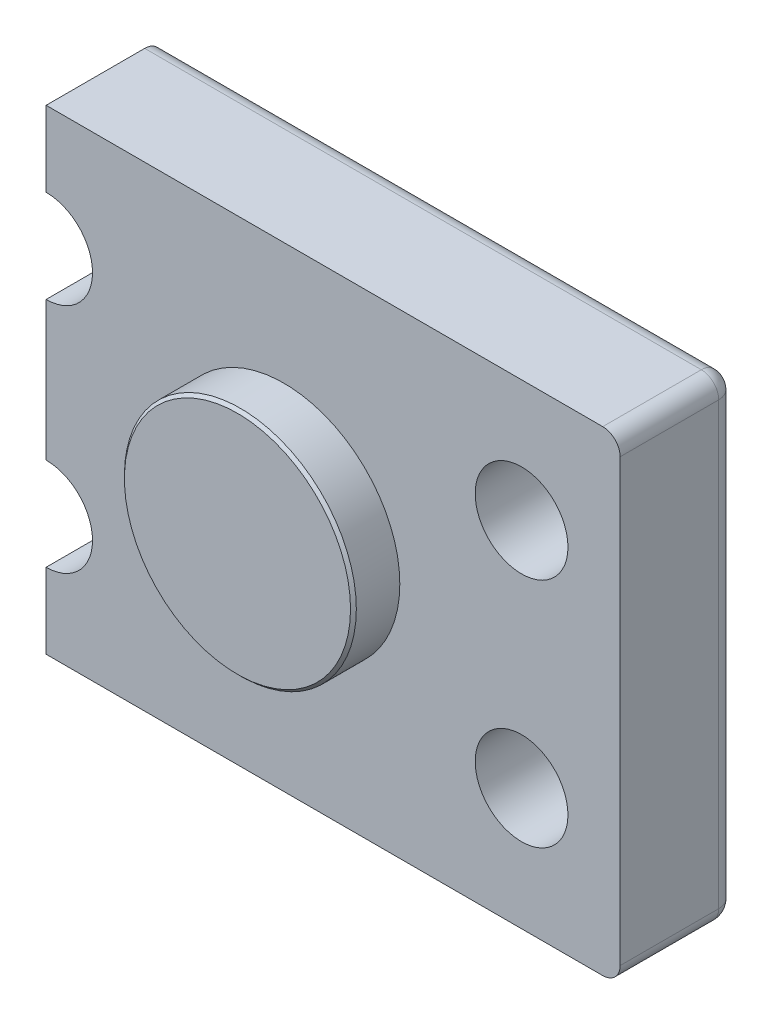
from build123d import *

# Parameters (mm, degrees)
BOSS_EXTRUDE1_DEPTH = 20
SKETCH2_R           = 8
CUT_EXTRUDE1_DEPTH  = 21
LPATTERN1_COUNT     = 2
LPATTERN1_PITCH     = 40
SKETCH3_R           = 20
BOSS_EXTRUDE2_DEPTH = 8
CHAMFER1_SIZE       = 0.5
FILLET1_R           = 3


with BuildPart() as part:
    # Sketch1 → Boss-Extrude1 (new body)
    with BuildSketch(Plane.XY):
        with BuildLine():
            Line((0, 69), (0, 82))
            Line((0, 82), (99, 82))
            Line((99, 82), (99, 0))
            Line((99, 0), (0, 0))
            Line((0, 0), (0, 13))
            ThreePointArc((0, 13), (8, 21), (0, 29))
            Line((0, 29), (0, 53))
            ThreePointArc((0, 53), (8, 61), (0, 69))
        make_face()
    extrude(amount=BOSS_EXTRUDE1_DEPTH)

    # Sketch2 → Cut-Extrude1 (cut, through all)
    with BuildSketch(Plane.XY.offset(20)):
        with Locations((82, 21)):
            Circle(SKETCH2_R)
    cut_extrude1 = extrude(amount=-CUT_EXTRUDE1_DEPTH, mode=Mode.SUBTRACT)

    # LPattern1: Cut-Extrude1 ×2
    with Locations(*[(0, i * LPATTERN1_PITCH, 0) for i in range(1, LPATTERN1_COUNT)]):
        add(cut_extrude1, mode=Mode.SUBTRACT)

    # Sketch3 → Boss-Extrude2 (add)
    with BuildSketch(Plane.XY.offset(20)):
        with Locations((41, 41)):
            Circle(SKETCH3_R)
    extrude(amount=BOSS_EXTRUDE2_DEPTH)

    # Chamfer1
    chamfer1_edges = [part.edges().sort_by_distance(p)[0] for p in [
        (21, 41, 28),
    ]]
    chamfer(chamfer1_edges, length=CHAMFER1_SIZE)

    # Fillet1
    fillet1_edges = [part.edges().sort_by_distance(p)[0] for p in [
        (49.5, 82, 0),
        (99, 41, 0),
        (49.5, 0, 0),
        (99, 82, 10),
        (99, 0, 10),
    ]]
    fillet(fillet1_edges, radius=FILLET1_R)


solid = part.part
